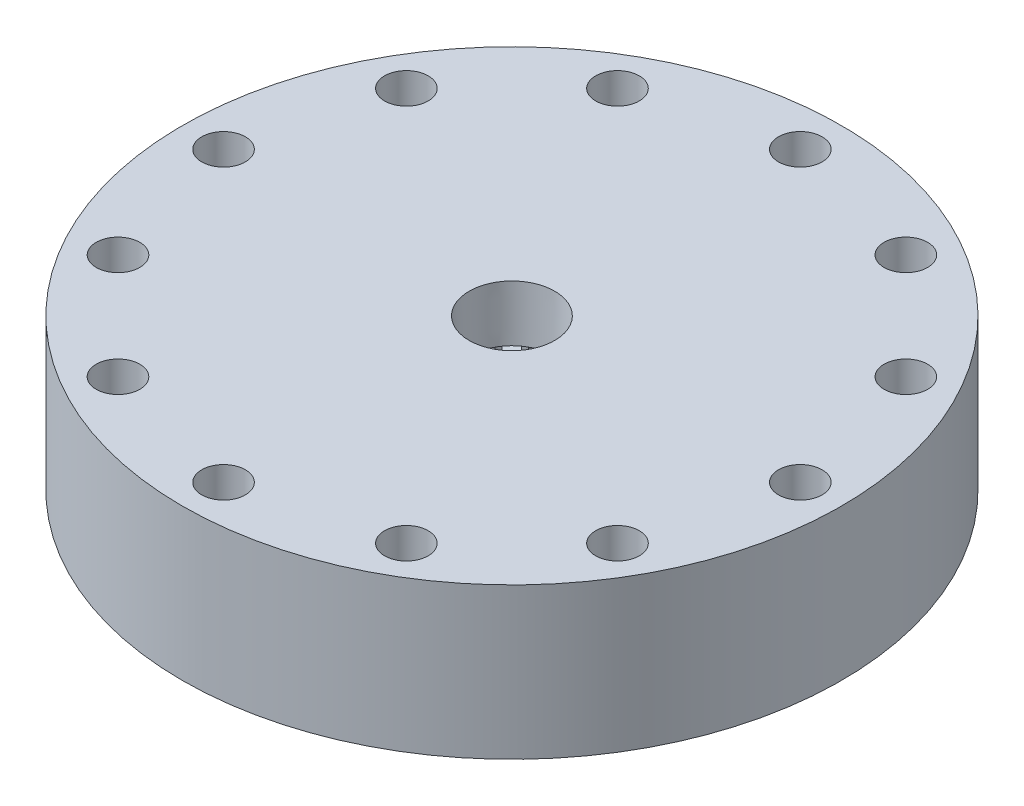
from build123d import *
from build123d.topology import SkipClean

# Parameters (mm, degrees)
CUT_EXTRUDE1_DEPTH                      = 20.6375
CUT_EXTRUDE3_REACH                      = 138.276
CUT_EXTRUDE3_END_RADIUS                 = 20.6375
CUT_EXTRUDE4_REACH                      = 126.282
CUT_EXTRUDE4_END_RADIUS                 = 11.1125
CIRPATTERN2_COUNT                       = 16
F_1_16_0_0625_DIAMETER_HOLE1_AT_2_COUNT = 2
F_1_16_0_0625_DIAMETER_HOLE1_AT_2_PITCH = 15.08125
CIRPATTERN3_COUNT                       = 16
F_3_8_CLEARANCE_HOLE1_D                 = 10.0838
CIRPATTERN4_COUNT                       = 12


with BuildPart() as part:
    # Sketch1 → Revolve1 (revolve)
    with BuildSketch(Plane.XY):
        Polygon((-76.2, 38.1), (0, 38.1), (0, 0), (-46.0375, 0), (-46.0375, 9.525), (-52.3875, 3.175), (-55.5625, 3.175), (-76.2, 3.175), align=None)
    revolve(axis=Axis((0, 38.1, 0), (0, -1, 0)))

    # Sketch6 → Cut-Extrude1 (cut)
    with BuildSketch(Plane.ZY.offset(46.0375)):
        Polygon((-3.175, 9.525), (3.175, 9.525), (3.175, 6.35), (0, 3.175), (-3.175, 6.35), align=None)
    cut_extrude1 = extrude(amount=-CUT_EXTRUDE1_DEPTH, mode=Mode.SUBTRACT)

    # Sketch7 → Cut-Revolve1 (revolve, cut)
    with BuildSketch(Plane.XY):
        with BuildLine():
            Line((26.9875, 7.9375), (26.9875, 4.7625))
            Line((26.9875, 4.7625), (25.4, 3.175))
            Line((25.4, 3.175), (23.8125, 4.7625))
            Line((23.8125, 4.7625), (23.8125, 7.9375))
            ThreePointArc((23.8125, 7.9375), (25.4, 9.525), (26.9875, 7.9375))
        make_face()
    revolve(axis=Axis((0, 74.05, 0), (0, -1, 0)), mode=Mode.SUBTRACT)

    # Sketch11 → 3_64 _0.04688_ Diameter Hole1 (revolve, cut)
    with SkipClean():  # the faces are left unmerged after this step: merging them gives an invalid solid
        with BuildSketch(Plane(origin=(-24.911946122, 0, -4.955294179), x_dir=(0, 0, -1), z_dir=(1, 0, 0))):
            Polygon((0, 0), (0, 6.707737992), (0.595376, 6.35), (0.595376, 0), align=None)
        f_3_64_0_04688_diameter_hole1 = revolve(axis=Axis((-24.911946122, -6.35, -4.955294179), (0, 1, 0)), mode=Mode.SUBTRACT)

    # Sketch27 → 1_32 _0.03125_ Diameter Hole1 (revolve, cut)
    with SkipClean():  # the faces are left unmerged after this step: merging them gives an invalid solid
        with BuildSketch(Plane(origin=(-44.45, 0, 0), x_dir=(0, 0, -1), z_dir=(1, 0, 0))):
            Polygon((0, 0), (0, 6.588466558), (0.396875, 6.35), (0.396875, 0), align=None)
        f_1_32_0_03125_diameter_hole1 = revolve(axis=Axis((-44.45, -6.35, 0), (0, 1, 0)), mode=Mode.SUBTRACT)

    # Sketch12 → Cut-Revolve2 (revolve, cut)
    with SkipClean():  # the faces are left unmerged after this step: merging them gives an invalid solid
        with BuildSketch(Plane.XY):
            Polygon((0, 7.9375), (-11.1125, 19.05), (-11.1125, 25.4), (0, 25.4), align=None)
            Polygon((-14.2875, 25.4), (-20.6375, 25.4), (-20.6375, 19.05), (-17.4625, 15.875), (-14.2875, 19.05), align=None)
            Polygon((-30.1625, 25.4), (-34.925, 25.4), (-34.925, 19.05), (-32.54375, 16.66875), (-30.1625, 19.05), align=None)
        revolve(axis=Axis((0, 74.05, 0), (0, -1, 0)), mode=Mode.SUBTRACT)

    # Cut-Extrude3: up to this cylinder (the profile starts outside it)
    with SkipClean():  # the faces are left unmerged after this step: merging them gives an invalid solid
        cut_extrude3_end = Plane(origin=(0, 23.389167, 0), z_dir=(0, 1, 0)) * Cylinder(CUT_EXTRUDE3_END_RADIUS, 318.827, mode=Mode.PRIVATE)
        # Sketch13 → Cut-Extrude3 (cut, up to the surface)
        with BuildSketch(Plane.ZY.offset(30.1625), mode=Mode.PRIVATE) as cut_extrude3_sk1:
            Polygon((1.5875, 25.4), (-1.5875, 25.4), (-1.5875, 22.225), (0, 20.6375), (1.5875, 22.225), align=None)
        cut_extrude3_tool1 = extrude(cut_extrude3_sk1.sketch, amount=-CUT_EXTRUDE3_REACH, mode=Mode.PRIVATE) - cut_extrude3_end
        cut_extrude3 = cut_extrude3_tool1.solids().sort_by_distance((-30.1625, 23.389167, 0))[0]
        add(cut_extrude3, mode=Mode.SUBTRACT)

    # Cut-Extrude4: up to this cylinder (the profile starts outside it)
    with SkipClean():  # the faces are left unmerged after this step: merging them gives an invalid solid
        cut_extrude4_end = Plane(origin=(0, 22.602976, 0), z_dir=(0, 1, 0)) * Cylinder(CUT_EXTRUDE4_END_RADIUS, 275.789, mode=Mode.PRIVATE)
        # Sketch14 → Cut-Extrude4 (cut, up to the surface)
        with BuildSketch(Plane.ZY.offset(14.2875), mode=Mode.PRIVATE) as cut_extrude4_sk1:
            Polygon((1.5875, 25.4), (-1.5875, 25.4), (-1.5875, 20.6375), (0, 19.05), (1.5875, 20.6375), align=None)
        cut_extrude4_tool1 = extrude(cut_extrude4_sk1.sketch, amount=-CUT_EXTRUDE4_REACH, mode=Mode.PRIVATE) - cut_extrude4_end
        cut_extrude4 = cut_extrude4_tool1.solids().sort_by_distance((-14.2875, 22.602976, 0))[0]
        add(cut_extrude4, mode=Mode.SUBTRACT)

    # CirPattern2: Cut-Extrude3, Cut-Extrude4 ×16 about axis
    with SkipClean():  # the faces are left unmerged after this step: merging them gives an invalid solid
        cirpattern2_axis = Axis((0, 74.05, 0), (0, -1, 0))
        add([cut_extrude3.rotate(cirpattern2_axis, i * 360 / CIRPATTERN2_COUNT) for i in range(1, CIRPATTERN2_COUNT)], mode=Mode.SUBTRACT)
        add([cut_extrude4.rotate(cirpattern2_axis, i * 360 / CIRPATTERN2_COUNT) for i in range(1, CIRPATTERN2_COUNT)], mode=Mode.SUBTRACT)

    # Sketch18 → 3_64 _0.04688_ Diameter Hole3 (revolve, cut)
    with SkipClean():  # the faces are left unmerged after this step: merging them gives an invalid solid
        with BuildSketch(Plane(origin=(-24.911946122, -4.7625, -4.955294179), x_dir=(0.4726593154061832, 0.30207048327149255, -0.8278566268961585), z_dir=(0.5437125053113416, 0.6393382697259166, 0.5437125053113416))):
            Polygon((0, 0), (0, 11.501987992), (0.595376, 11.14425), (0.595376, 0), align=None)
        f_3_64_0_04688_diameter_hole3 = revolve(axis=Axis((-20.508094613, -9.252628061, -4.07931365), (-0.6935199226610744, 0.7071067811865464, -0.13794968964147447)), mode=Mode.SUBTRACT)

    # Sketch21 → 1_16 _0.0625_ Diameter Hole1 (revolve, cut)
    with SkipClean():  # the faces are left unmerged after this step: merging them gives an invalid solid
        with BuildSketch(Plane(origin=(-31.918430969, 19.05, -6.348970667), x_dir=(0, 0, 1), z_dir=(1, 0, 0))):
            Polygon((0, 0), (0, 16.478933116), (0.79375, 16.002), (0.79375, 0), align=None)
        f_1_16_0_0625_diameter_hole1 = revolve(axis=Axis((-31.918430969, 25.4, -6.348970667), (0, -1, 0)), mode=Mode.SUBTRACT)

    # 1_16 _0.0625_ Diameter Hole1 at 2: 1_16 _0.0625_ Diameter Hole1 ×2
    with SkipClean():  # the faces are left unmerged after this step: merging them gives an invalid solid
        with Locations(*[Vector(0.9807852804032318, 0, 0.19509032201612173) * (i * F_1_16_0_0625_DIAMETER_HOLE1_AT_2_PITCH) for i in range(1, F_1_16_0_0625_DIAMETER_HOLE1_AT_2_COUNT)]):
            add(f_1_16_0_0625_diameter_hole1, mode=Mode.SUBTRACT)

    # Mirror2: 3_64 _0.04688_ Diameter Hole3 across plane
    with SkipClean():  # the faces are left unmerged after this step: merging them gives an invalid solid
        add(f_3_64_0_04688_diameter_hole3.mirror(Plane(origin=(-24.911946122, 0, -4.955294179), x_dir=(-0.19509032201613216, 0, 0.9807852804032297), z_dir=(-0.9807852804032297, 0, -0.19509032201613216))), mode=Mode.SUBTRACT)

    # CirPattern3: Cut-Extrude1, 3_64 _0.04688_ Diameter Hole1, 1_32 _0.03125_ Diameter Hole1, 3_64 _0.04688_ Diameter Hole3, 1_16 _0.0625_ Diameter Hole1 ×16 about axis
    cirpattern3_axis = Axis((0, 74.05, 0), (0, -1, 0))
    add([cut_extrude1.rotate(cirpattern3_axis, i * 360 / CIRPATTERN3_COUNT) for i in range(1, CIRPATTERN3_COUNT)], mode=Mode.SUBTRACT)
    add([f_3_64_0_04688_diameter_hole1.rotate(cirpattern3_axis, i * 360 / CIRPATTERN3_COUNT) for i in range(1, CIRPATTERN3_COUNT)], mode=Mode.SUBTRACT)
    add([f_1_32_0_03125_diameter_hole1.rotate(cirpattern3_axis, i * 360 / CIRPATTERN3_COUNT) for i in range(1, CIRPATTERN3_COUNT)], mode=Mode.SUBTRACT)
    add([f_3_64_0_04688_diameter_hole3.rotate(cirpattern3_axis, i * 360 / CIRPATTERN3_COUNT) for i in range(1, CIRPATTERN3_COUNT)], mode=Mode.SUBTRACT)
    add([f_1_16_0_0625_diameter_hole1.rotate(cirpattern3_axis, i * 360 / CIRPATTERN3_COUNT) for i in range(1, CIRPATTERN3_COUNT)], mode=Mode.SUBTRACT)

    # CirPattern3 copy 1 sketch → CirPattern3 copy 1 (revolve, cut)
    with BuildSketch(Plane(origin=(-14.519538105, 19.05, -9.701645194), x_dir=(-0.3826834323650898, 0, 0.9238795325112867), z_dir=(0.9238795325112867, 0, 0.3826834323650898))):
        Polygon((0, 0), (0, 16.478933116), (0.79375, 16.002), (0.79375, 0), align=None)
    revolve(axis=Axis((-14.519538105, 25.4, -9.701645194), (0, -1, 0)), mode=Mode.SUBTRACT)

    # CirPattern3 copy 2 sketch → CirPattern3 copy 2 (revolve, cut)
    with BuildSketch(Plane(origin=(-9.701645194, 19.05, -14.519538105), x_dir=(-0.7071067811865475, 0, 0.7071067811865476), z_dir=(0.7071067811865476, 0, 0.7071067811865475))):
        Polygon((0, 0), (0, 16.478933116), (0.79375, 16.002), (0.79375, 0), align=None)
    revolve(axis=Axis((-9.701645194, 25.4, -14.519538105), (0, -1, 0)), mode=Mode.SUBTRACT)

    # CirPattern3 copy 3 sketch → CirPattern3 copy 3 (revolve, cut)
    with BuildSketch(Plane(origin=(-3.406764748, 19.05, -17.126962959), x_dir=(-0.9238795325112867, 0, 0.38268343236508984), z_dir=(0.38268343236508984, 0, 0.9238795325112867))):
        Polygon((0, 0), (0, 16.478933116), (0.79375, 16.002), (0.79375, 0), align=None)
    revolve(axis=Axis((-3.406764748, 25.4, -17.126962959), (0, -1, 0)), mode=Mode.SUBTRACT)

    # CirPattern3 copy 4 sketch → CirPattern3 copy 4 (revolve, cut)
    with BuildSketch(Plane(origin=(3.406764748, 19.05, -17.126962959), x_dir=(-1, 0, 0), z_dir=(0, 0, 1))):
        Polygon((0, 0), (0, 16.478933116), (0.79375, 16.002), (0.79375, 0), align=None)
    revolve(axis=Axis((3.406764748, 25.4, -17.126962959), (0, -1, 0)), mode=Mode.SUBTRACT)

    # CirPattern3 copy 5 sketch → CirPattern3 copy 5 (revolve, cut)
    with BuildSketch(Plane(origin=(9.701645194, 19.05, -14.519538105), x_dir=(-0.9238795325112867, 0, -0.3826834323650897), z_dir=(-0.3826834323650897, 0, 0.9238795325112867))):
        Polygon((0, 0), (0, 16.478933116), (0.79375, 16.002), (0.79375, 0), align=None)
    revolve(axis=Axis((9.701645194, 25.4, -14.519538105), (0, -1, 0)), mode=Mode.SUBTRACT)

    # CirPattern3 copy 6 sketch → CirPattern3 copy 6 (revolve, cut)
    with BuildSketch(Plane(origin=(14.519538105, 19.05, -9.701645194), x_dir=(-0.7071067811865476, 0, -0.7071067811865475), z_dir=(-0.7071067811865475, 0, 0.7071067811865476))):
        Polygon((0, 0), (0, 16.478933116), (0.79375, 16.002), (0.79375, 0), align=None)
    revolve(axis=Axis((14.519538105, 25.4, -9.701645194), (0, -1, 0)), mode=Mode.SUBTRACT)

    # CirPattern3 copy 7 sketch → CirPattern3 copy 7 (revolve, cut)
    with BuildSketch(Plane(origin=(17.126962959, 19.05, -3.406764748), x_dir=(-0.3826834323650899, 0, -0.9238795325112867), z_dir=(-0.9238795325112867, 0, 0.3826834323650899))):
        Polygon((0, 0), (0, 16.478933116), (0.79375, 16.002), (0.79375, 0), align=None)
    revolve(axis=Axis((17.126962959, 25.4, -3.406764748), (0, -1, 0)), mode=Mode.SUBTRACT)

    # CirPattern3 copy 8 sketch → CirPattern3 copy 8 (revolve, cut)
    with BuildSketch(Plane(origin=(17.126962959, 19.05, 3.406764748), x_dir=(0, 0, -1), z_dir=(-1, 0, 0))):
        Polygon((0, 0), (0, 16.478933116), (0.79375, 16.002), (0.79375, 0), align=None)
    revolve(axis=Axis((17.126962959, 25.4, 3.406764748), (0, -1, 0)), mode=Mode.SUBTRACT)

    # CirPattern3 copy 9 sketch → CirPattern3 copy 9 (revolve, cut)
    with BuildSketch(Plane(origin=(14.519538105, 19.05, 9.701645194), x_dir=(0.38268343236508967, 0, -0.9238795325112868), z_dir=(-0.9238795325112868, 0, -0.38268343236508967))):
        Polygon((0, 0), (0, 16.478933116), (0.79375, 16.002), (0.79375, 0), align=None)
    revolve(axis=Axis((14.519538105, 25.4, 9.701645194), (0, -1, 0)), mode=Mode.SUBTRACT)

    # CirPattern3 copy 10 sketch → CirPattern3 copy 10 (revolve, cut)
    with BuildSketch(Plane(origin=(9.701645194, 19.05, 14.519538105), x_dir=(0.7071067811865475, 0, -0.7071067811865477), z_dir=(-0.7071067811865477, 0, -0.7071067811865475))):
        Polygon((0, 0), (0, 16.478933116), (0.79375, 16.002), (0.79375, 0), align=None)
    revolve(axis=Axis((9.701645194, 25.4, 14.519538105), (0, -1, 0)), mode=Mode.SUBTRACT)

    # CirPattern3 copy 11 sketch → CirPattern3 copy 11 (revolve, cut)
    with BuildSketch(Plane(origin=(3.406764748, 19.05, 17.126962959), x_dir=(0.9238795325112868, 0, -0.3826834323650895), z_dir=(-0.3826834323650895, 0, -0.9238795325112868))):
        Polygon((0, 0), (0, 16.478933116), (0.79375, 16.002), (0.79375, 0), align=None)
    revolve(axis=Axis((3.406764748, 25.4, 17.126962959), (0, -1, 0)), mode=Mode.SUBTRACT)

    # CirPattern3 copy 12 sketch → CirPattern3 copy 12 (revolve, cut)
    with BuildSketch(Plane(origin=(-3.406764748, 19.05, 17.126962959), x_dir=(1, 0, 0), z_dir=(0, 0, -1))):
        Polygon((0, 0), (0, 16.478933116), (0.79375, 16.002), (0.79375, 0), align=None)
    revolve(axis=Axis((-3.406764748, 25.4, 17.126962959), (0, -1, 0)), mode=Mode.SUBTRACT)

    # CirPattern3 copy 13 sketch → CirPattern3 copy 13 (revolve, cut)
    with BuildSketch(Plane(origin=(-9.701645194, 19.05, 14.519538105), x_dir=(0.9238795325112866, 0, 0.38268343236509), z_dir=(0.38268343236509, 0, -0.9238795325112866))):
        Polygon((0, 0), (0, 16.478933116), (0.79375, 16.002), (0.79375, 0), align=None)
    revolve(axis=Axis((-9.701645194, 25.4, 14.519538105), (0, -1, 0)), mode=Mode.SUBTRACT)

    # CirPattern3 copy 14 sketch → CirPattern3 copy 14 (revolve, cut)
    with BuildSketch(Plane(origin=(-14.519538105, 19.05, 9.701645194), x_dir=(0.7071067811865477, 0, 0.7071067811865474), z_dir=(0.7071067811865474, 0, -0.7071067811865477))):
        Polygon((0, 0), (0, 16.478933116), (0.79375, 16.002), (0.79375, 0), align=None)
    revolve(axis=Axis((-14.519538105, 25.4, 9.701645194), (0, -1, 0)), mode=Mode.SUBTRACT)

    # CirPattern3 copy 15 sketch → CirPattern3 copy 15 (revolve, cut)
    with BuildSketch(Plane(origin=(-17.126962959, 19.05, 3.406764748), x_dir=(0.38268343236508956, 0, 0.9238795325112868), z_dir=(0.9238795325112868, 0, -0.38268343236508956))):
        Polygon((0, 0), (0, 16.478933116), (0.79375, 16.002), (0.79375, 0), align=None)
    revolve(axis=Axis((-17.126962959, 25.4, 3.406764748), (0, -1, 0)), mode=Mode.SUBTRACT)

    # CirPattern3 copy 16 sketch → CirPattern3 copy 16 (revolve, cut)
    with BuildSketch(Plane(origin=(-21.119328152, -4.7625, -14.111483919), x_dir=(0.2511624276137993, 0.30207048327149255, -0.9196036418431967), z_dir=(-0.7689255990431528, 0.6393382697259166, -6.106226635438361e-15))):
        Polygon((0, 0), (0, -11.501987992), (0.595376, -11.14425), (0.595376, 0), align=None)
    revolve(axis=Axis((-24.85273319, -9.252628061, -16.606065412), (-0.5879378012096788, -0.7071067811865464, -0.3928474791935541)), mode=Mode.SUBTRACT)

    # CirPattern3 copy 17 sketch → CirPattern3 copy 17 (revolve, cut)
    with BuildSketch(Plane(origin=(-14.111483919, -4.7625, -21.119328152), x_dir=(0.583960904284228, 0.30207048327149255, -0.7534872828413721), z_dir=(-0.7103946229799468, 0.6393382697259166, -0.294255087475222))):
        Polygon((0, 0), (0, -11.501987992), (0.595376, -11.14425), (0.595376, 0), align=None)
    revolve(axis=Axis((-16.606065412, -9.252628061, -24.85273319), (-0.39284747919354945, -0.7071067811865464, -0.5879378012096819)), mode=Mode.SUBTRACT)

    # CirPattern3 copy 18 sketch → CirPattern3 copy 18 (revolve, cut)
    with BuildSketch(Plane(origin=(-4.955294179, -4.7625, -24.911946122), x_dir=(0.8278566268961622, 0.30207048327149255, -0.4726593154061766), z_dir=(-0.5437125053113373, 0.6393382697259166, -0.5437125053113459))):
        Polygon((0, 0), (0, -11.501987992), (0.595376, -11.14425), (0.595376, 0), align=None)
    revolve(axis=Axis((-5.831274708, -9.252628061, -29.315797631), (-0.13794968964146898, -0.7071067811865464, -0.6935199226610754)), mode=Mode.SUBTRACT)

    # CirPattern3 copy 19 sketch → CirPattern3 copy 19 (revolve, cut)
    with BuildSketch(Plane(origin=(4.955294179, -4.7625, -24.911946122), x_dir=(0.9457186826021663, 0.30207048327149255, -0.1198732518677545), z_dir=(-0.2942550874752109, 0.6393382697259166, -0.7103946229799514))):
        Polygon((0, 0), (0, -11.501987992), (0.595376, -11.14425), (0.595376, 0), align=None)
    revolve(axis=Axis((5.831274708, -9.252628061, -29.315797631), (0.1379496896414745, -0.7071067811865464, -0.6935199226610743)), mode=Mode.SUBTRACT)

    # CirPattern3 copy 20 sketch → CirPattern3 copy 20 (revolve, cut)
    with BuildSketch(Plane(origin=(14.111483919, -4.7625, -21.119328152), x_dir=(0.9196036418431965, 0.3020704832714925, 0.2511624276137992), z_dir=(6.050715484207103e-15, 0.6393382697259165, -0.7689255990431527))):
        Polygon((0, 0), (0, -11.501987992), (0.595376, -11.14425), (0.595376, 0), align=None)
    revolve(axis=Axis((16.606065412, -9.252628061, -24.85273319), (0.3928474791935541, -0.7071067811865462, -0.5879378012096788)), mode=Mode.SUBTRACT)

    # CirPattern3 copy 21 sketch → CirPattern3 copy 21 (revolve, cut)
    with BuildSketch(Plane(origin=(21.119328152, -4.7625, -14.111483919), x_dir=(0.7534872828413721, 0.30207048327149255, 0.583960904284228), z_dir=(0.294255087475222, 0.6393382697259166, -0.7103946229799468))):
        Polygon((0, 0), (0, -11.501987992), (0.595376, -11.14425), (0.595376, 0), align=None)
    revolve(axis=Axis((24.85273319, -9.252628061, -16.606065412), (0.5879378012096819, -0.7071067811865464, -0.39284747919354945)), mode=Mode.SUBTRACT)

    # CirPattern3 copy 22 sketch → CirPattern3 copy 22 (revolve, cut)
    with BuildSketch(Plane(origin=(24.911946122, -4.7625, -4.955294179), x_dir=(0.4726593154061767, 0.30207048327149255, 0.8278566268961622), z_dir=(0.5437125053113459, 0.6393382697259166, -0.5437125053113373))):
        Polygon((0, 0), (0, -11.501987992), (0.595376, -11.14425), (0.595376, 0), align=None)
    revolve(axis=Axis((29.315797631, -9.252628061, -5.831274708), (0.6935199226610755, -0.7071067811865464, -0.137949689641469)), mode=Mode.SUBTRACT)

    # CirPattern3 copy 23 sketch → CirPattern3 copy 23 (revolve, cut)
    with BuildSketch(Plane(origin=(24.911946122, -4.7625, 4.955294179), x_dir=(0.11987325186775455, 0.30207048327149255, 0.9457186826021662), z_dir=(0.7103946229799514, 0.6393382697259166, -0.29425508747521095))):
        Polygon((0, 0), (0, -11.501987992), (0.595376, -11.14425), (0.595376, 0), align=None)
    revolve(axis=Axis((29.315797631, -9.252628061, 5.831274708), (0.6935199226610743, -0.7071067811865464, 0.13794968964147444)), mode=Mode.SUBTRACT)

    # CirPattern3 copy 24 sketch → CirPattern3 copy 24 (revolve, cut)
    with BuildSketch(Plane(origin=(21.119328152, -4.7625, 14.111483919), x_dir=(-0.25116242761379903, 0.30207048327149255, 0.9196036418431968), z_dir=(0.7689255990431527, 0.6393382697259166, 5.995204332975845e-15))):
        Polygon((0, 0), (0, -11.501987992), (0.595376, -11.14425), (0.595376, 0), align=None)
    revolve(axis=Axis((24.85273319, -9.252628061, 16.606065412), (0.5879378012096788, -0.7071067811865464, 0.39284747919355406)), mode=Mode.SUBTRACT)

    # CirPattern3 copy 25 sketch → CirPattern3 copy 25 (revolve, cut)
    with BuildSketch(Plane(origin=(14.111483919, -4.7625, 21.119328152), x_dir=(-0.5839609042842279, 0.30207048327149255, 0.7534872828413723), z_dir=(0.7103946229799469, 0.6393382697259166, 0.294255087475222))):
        Polygon((0, 0), (0, -11.501987992), (0.595376, -11.14425), (0.595376, 0), align=None)
    revolve(axis=Axis((16.606065412, -9.252628061, 24.85273319), (0.39284747919354945, -0.7071067811865464, 0.5879378012096819)), mode=Mode.SUBTRACT)

    # CirPattern3 copy 26 sketch → CirPattern3 copy 26 (revolve, cut)
    with BuildSketch(Plane(origin=(4.955294179, -4.7625, 24.911946122), x_dir=(-0.8278566268961624, 0.30207048327149255, 0.47265931540617634), z_dir=(0.5437125053113372, 0.6393382697259166, 0.543712505311346))):
        Polygon((0, 0), (0, -11.501987992), (0.595376, -11.14425), (0.595376, 0), align=None)
    revolve(axis=Axis((5.831274708, -9.252628061, 29.315797631), (0.13794968964146878, -0.7071067811865464, 0.6935199226610754)), mode=Mode.SUBTRACT)

    # CirPattern3 copy 27 sketch → CirPattern3 copy 27 (revolve, cut)
    with BuildSketch(Plane(origin=(-4.955294179, -4.7625, 24.911946122), x_dir=(-0.9457186826021664, 0.30207048327149255, 0.1198732518677546), z_dir=(0.294255087475211, 0.6393382697259166, 0.7103946229799514))):
        Polygon((0, 0), (0, -11.501987992), (0.595376, -11.14425), (0.595376, 0), align=None)
    revolve(axis=Axis((-5.831274708, -9.252628061, 29.315797631), (-0.1379496896414744, -0.7071067811865464, 0.6935199226610744)), mode=Mode.SUBTRACT)

    # CirPattern3 copy 28 sketch → CirPattern3 copy 28 (revolve, cut)
    with BuildSketch(Plane(origin=(-14.111483919, -4.7625, 21.119328152), x_dir=(-0.9196036418431964, 0.30207048327149255, -0.25116242761379953), z_dir=(-6.2727600891321345e-15, 0.6393382697259166, 0.7689255990431527))):
        Polygon((0, 0), (0, -11.501987992), (0.595376, -11.14425), (0.595376, 0), align=None)
    revolve(axis=Axis((-16.606065412, -9.252628061, 24.85273319), (-0.3928474791935542, -0.7071067811865464, 0.5879378012096786)), mode=Mode.SUBTRACT)

    # CirPattern3 copy 29 sketch → CirPattern3 copy 29 (revolve, cut)
    with BuildSketch(Plane(origin=(-21.119328152, -4.7625, 14.111483919), x_dir=(-0.7534872828413723, 0.30207048327149255, -0.5839609042842276), z_dir=(-0.29425508747522194, 0.6393382697259166, 0.7103946229799468))):
        Polygon((0, 0), (0, -11.501987992), (0.595376, -11.14425), (0.595376, 0), align=None)
    revolve(axis=Axis((-24.85273319, -9.252628061, 16.606065412), (-0.5879378012096818, -0.7071067811865464, 0.3928474791935495)), mode=Mode.SUBTRACT)

    # CirPattern3 copy 30 sketch → CirPattern3 copy 30 (revolve, cut)
    with BuildSketch(Plane(origin=(-24.911946122, -4.7625, 4.955294179), x_dir=(-0.4726593154061764, 0.30207048327149255, -0.8278566268961624), z_dir=(-0.543712505311346, 0.6393382697259166, 0.5437125053113372))):
        Polygon((0, 0), (0, -11.501987992), (0.595376, -11.14425), (0.595376, 0), align=None)
    revolve(axis=Axis((-29.315797631, -9.252628061, 5.831274708), (-0.6935199226610754, -0.7071067811865464, 0.13794968964146878)), mode=Mode.SUBTRACT)

    # 3_8 Clearance Hole1 (through all)
    with Locations(Plane(origin=(0, 38.1, 0), x_dir=(1, 0, 0), z_dir=(0, 1, 0))):
        with Locations((66.675, 0)):
            f_3_8_clearance_hole1 = Hole(F_3_8_CLEARANCE_HOLE1_D / 2)

    # CirPattern4: 3_8 Clearance Hole1 ×12 about axis
    cirpattern4_axis = Axis((0, 74.05, 0), (0, -1, 0))
    for i in range(1, CIRPATTERN4_COUNT):
        add(f_3_8_clearance_hole1.rotate(cirpattern4_axis, i * 360 / CIRPATTERN4_COUNT), mode=Mode.SUBTRACT)

    # Sketch25 → 1_2 NPT Tapped Hole2 (revolve, cut)
    with BuildSketch(Plane(origin=(0, 38.1, 0), x_dir=(0, 0, 1), z_dir=(1, 0, 0))):
        Polygon((0, 0), (0, 21.239543693), (8.9281, 15.875), (8.9281, 13.462), (9.479726792, 13.462), (9.8827971, 0), align=None)
    revolve(axis=Axis((0, 44.45, 0), (0, -1, 0)), mode=Mode.SUBTRACT)

    # Sketch5 → 1_2 NPT Tapped Hole1 (revolve, cut)
    with BuildSketch(Plane(origin=(0, 38.1, 0), x_dir=(0, 0, 1), z_dir=(1, 0, 0))):
        Polygon((0, 0), (0, 24.414543693), (8.9281, 19.05), (8.9281, 13.462), (9.479726792, 13.462), (9.8827971, 0), align=None)
    revolve(axis=Axis((0, 44.45, 0), (0, -1, 0)), mode=Mode.SUBTRACT)


solid = part.part
